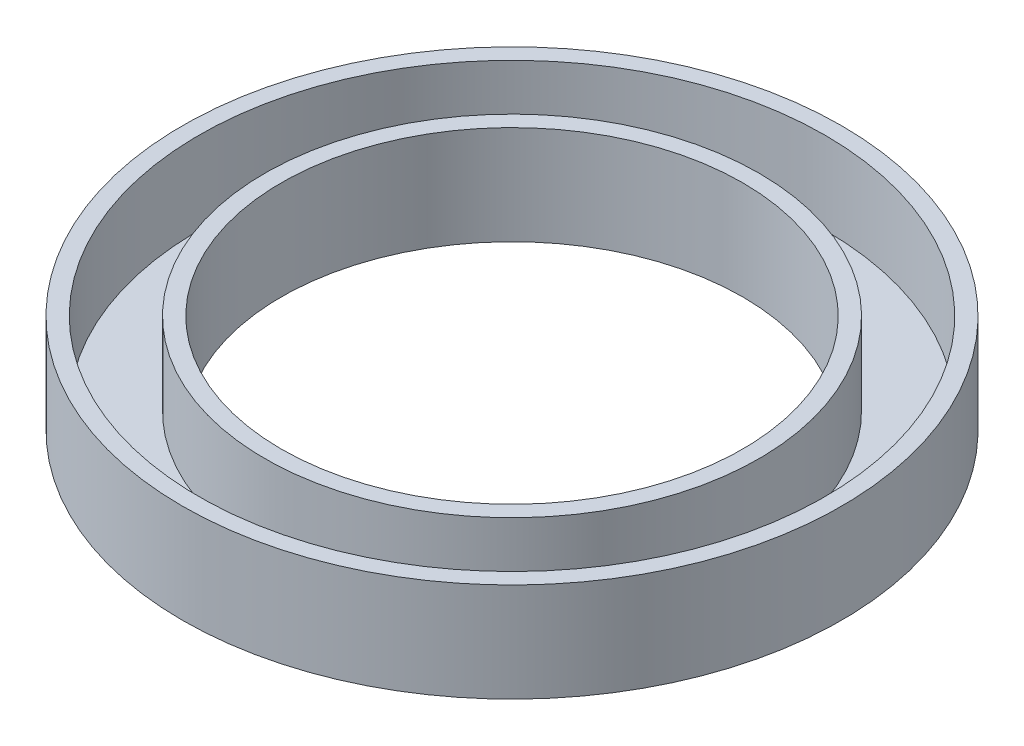
from build123d import *


with BuildPart() as part:
    # Sketch1 → Revolve1 (revolve)
    with BuildSketch(Plane.XY):
        Polygon((-15.875, 4.7625), (-15.875, 0), (-11.1125, 0), (-11.1125, 4.7625), (-11.90625, 4.7625), (-11.90625, 0.79375), (-15.08125, 0.79375), (-15.08125, 4.7625), align=None)
    revolve(axis=Axis((0, 0, 0), (0, 1, 0)))


solid = part.part
